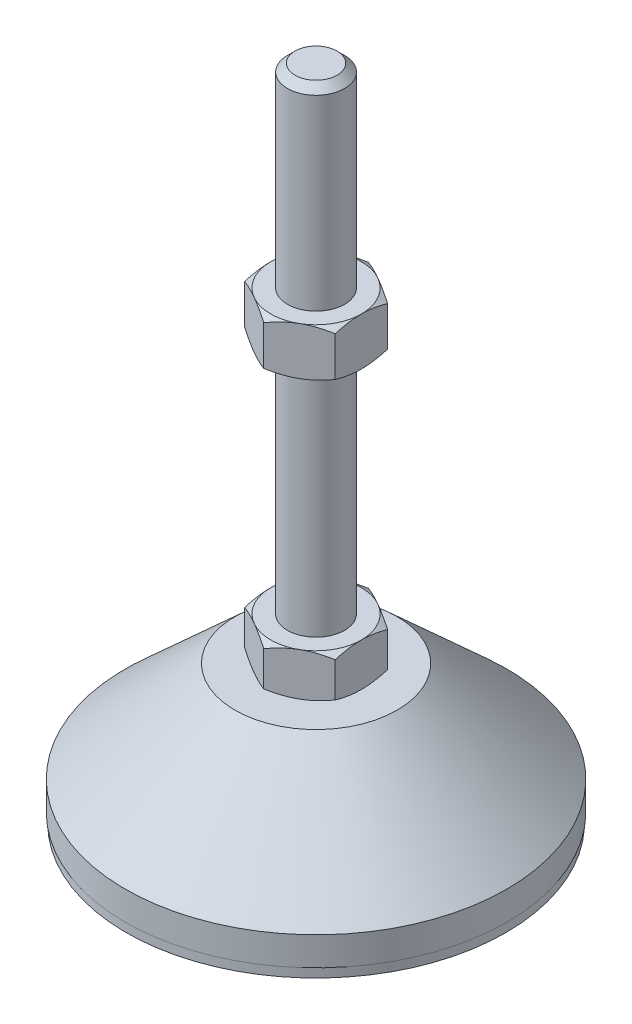
from build123d import *

# Parameters (mm, degrees)
EXTRUDE_1_DEPTH = 9
EXTRUDE_2_DEPTH = 10


with BuildPart() as part:
    # Эскиз1 → Повернуть1 (revolve)
    with BuildSketch(Plane.XY, mode=Mode.PRIVATE) as revolve_1_sk:
        Polygon((0, 0), (-39.8, 0), (-39.8, 2), (-40, 2), (-40, 8), (-17, 29), (-6, 29), (-6, 38), (-6, 136.4), (-4.4, 138), (0, 138), align=None)
    revolve(revolve_1_sk.sketch.rotate(Axis((0, 0, 0), (0, 1, 0)), 180), axis=Axis((0, 0, 0), (0, 1, 0)))  # turned: the seam where the file's is

    # Эскиз2 → Бобышка-Вытянуть1 (add)
    with BuildSketch(Plane(origin=(0, 29, 0), x_dir=(1, 0, 0), z_dir=(0, 1, 0))):
        Polygon((0, 10.969655115), (-9.5, 5.484827557), (-9.5, -5.484827557), (0, -10.969655115), (9.5, -5.484827557), (9.5, 5.484827557), align=None)
    extrude(amount=EXTRUDE_1_DEPTH)

    # Эскиз3 → Бобышка-Вытянуть2 (add)
    with BuildSketch(Plane(origin=(0, 87.2, 0), x_dir=(1, 0, 0), z_dir=(0, 1, 0))):
        Polygon((9.5, 5.484827557), (0, 10.969655115), (-9.5, 5.484827557), (-9.5, -5.484827557), (0, -10.969655115), (9.5, -5.484827557), align=None)
    extrude(amount=EXTRUDE_2_DEPTH)

    # Эскиз4 → Вырез-Повернуть2 (revolve, cut)
    with BuildSketch(Plane.XY, mode=Mode.PRIVATE) as cut_revolve_2_sk:
        Polygon((-18.160254038, 97.2), (-9.5, 97.2), (-18.160254038, 92.2), align=None)
        Polygon((-18.160254038, 87.2), (-18.160254038, 92.2), (-9.5, 87.2), align=None)
        Polygon((-17.294228634, 38), (-17.294228634, 33.5), (-9.5, 38), align=None)
        Polygon((-17.294228634, 33.5), (-17.294228634, 29), (-9.5, 29), align=None)
    revolve(cut_revolve_2_sk.sketch.rotate(Axis((0, 138, 0), (0, -1, 0)), 180), axis=Axis((0, 138, 0), (0, -1, 0)), mode=Mode.SUBTRACT)  # turned: the seam where the file's is


solid = part.part
